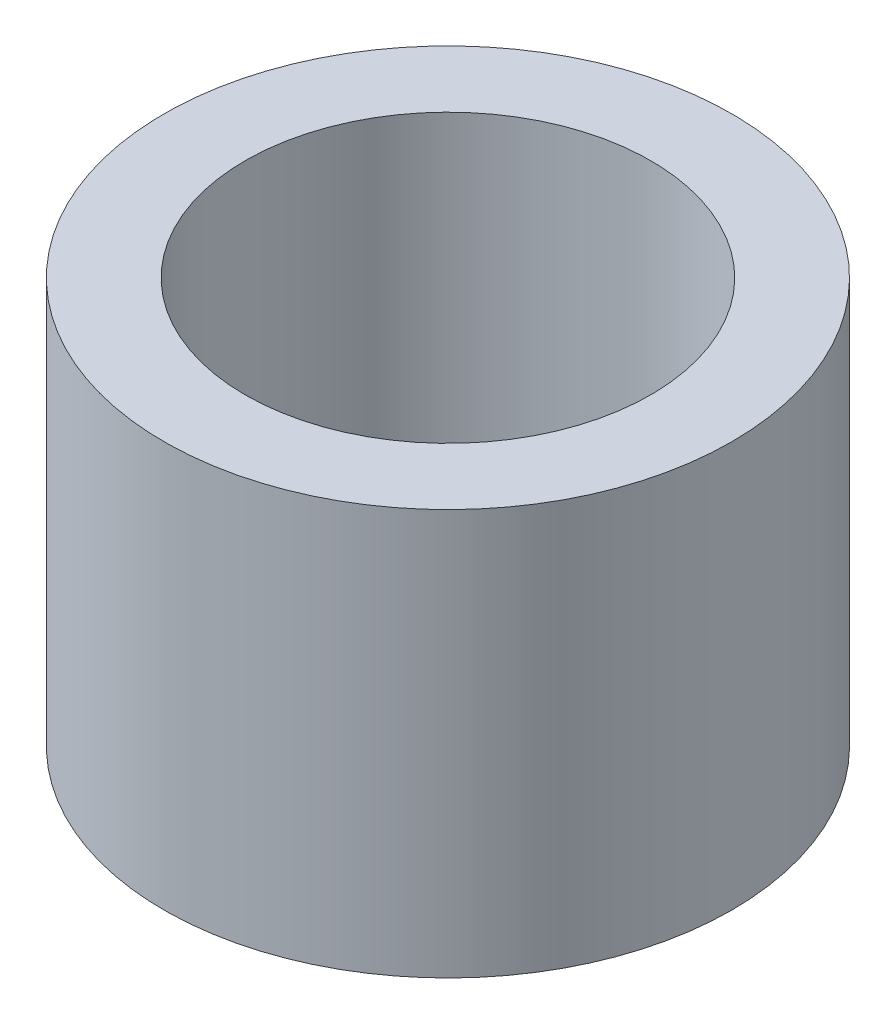
from build123d import *

# Parameters (mm, degrees)
SKETCH_1_R      = 35
SKETCH_1_R_2    = 25
EXTRUDE_1_DEPTH = 50


with BuildPart() as part:
    # Эскиз1 → Вытянуть-Тонкостенный1 (new body)
    with BuildSketch(Plane(origin=(0, 0, 0), x_dir=(1, 0, 0), z_dir=(0, 1, 0))):
        Circle(SKETCH_1_R)
        Circle(SKETCH_1_R_2, mode=Mode.SUBTRACT)
    extrude(amount=EXTRUDE_1_DEPTH)


solid = part.part
